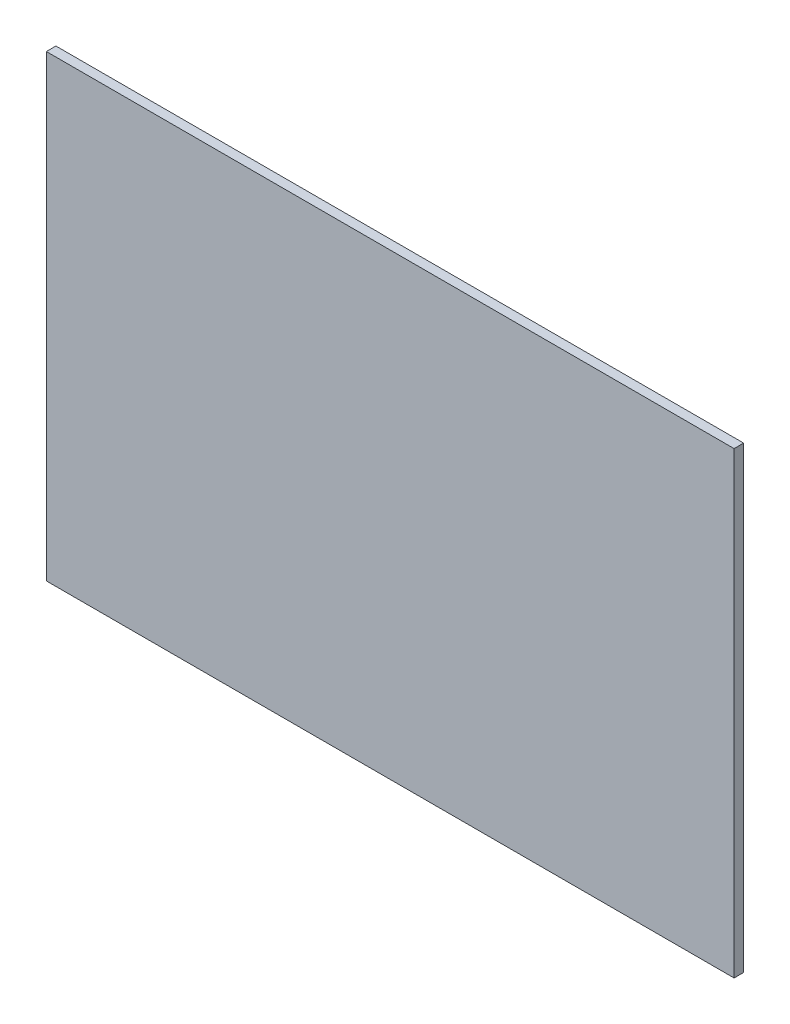
from build123d import *

# Parameters (mm, degrees)
SKETCH1_W           = 1828.8
SKETCH1_H           = 1219.2
BOSS_EXTRUDE1_DEPTH = 25.4


with BuildPart() as part:
    # Sketch1 → Boss-Extrude1 (new body)
    with BuildSketch(Plane.XY):
        with Locations((914.4, -609.6)):
            Rectangle(SKETCH1_W, SKETCH1_H)
    extrude(amount=BOSS_EXTRUDE1_DEPTH)


solid = part.part
